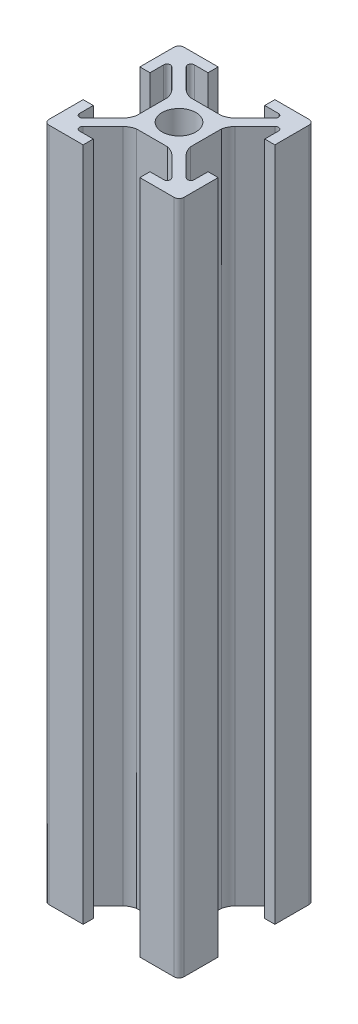
from build123d import *

# Parameters (mm, degrees)
SKETCH1_R           = 2.5
BOSS_EXTRUDE1_DEPTH = 100


with BuildPart() as part:
    # Sketch1 → Boss-Extrude1 (new body)
    with BuildSketch(Plane(origin=(0, 0, 0), x_dir=(1, 0, 0), z_dir=(0, 1, 0))):
        with BuildLine():
            Line((-3.610984523, 4.671644695), (-6.585786438, 7.646446609))
            ThreePointArc((-6.585786438, 7.646446609), (-6.694172813, 8.191341716), (-6.232233047, 8.5))
            Line((-6.232233047, 8.5), (-4.2, 8.5))
            Line((-4.2, 8.5), (-4.2, 10))
            Line((-4.2, 10), (-9.25, 10))
            ThreePointArc((-9.25, 10), (-9.780330086, 9.780330086), (-10, 9.25))
            Line((-10, 9.25), (-10, 4.2))
            Line((-10, 4.2), (-8.5, 4.2))
            Line((-8.5, 4.2), (-8.5, 6.232233047))
            ThreePointArc((-8.5, 6.232233047), (-8.191341716, 6.694172813), (-7.646446609, 6.585786438))
            Line((-7.646446609, 6.585786438), (-4.671644695, 3.610984523))
            ThreePointArc((-4.671644695, 3.610984523), (-4.244383234, 2.985253206), (-4, 2.268058063))
            Line((-4, 2.268058063), (-4, -2.268058063))
            ThreePointArc((-4, -2.268058063), (-4.244383234, -2.985253206), (-4.671644695, -3.610984523))
            Line((-4.671644695, -3.610984523), (-7.646446609, -6.585786438))
            ThreePointArc((-7.646446609, -6.585786438), (-8.191341716, -6.694172813), (-8.5, -6.232233047))
            Line((-8.5, -6.232233047), (-8.5, -4.2))
            Line((-8.5, -4.2), (-10, -4.2))
            Line((-10, -4.2), (-10, -9.25))
            ThreePointArc((-10, -9.25), (-9.780330086, -9.780330086), (-9.25, -10))
            Line((-9.25, -10), (-4.2, -10))
            Line((-4.2, -10), (-4.2, -8.5))
            Line((-4.2, -8.5), (-6.232233047, -8.5))
            ThreePointArc((-6.232233047, -8.5), (-6.694172813, -8.191341716), (-6.585786438, -7.646446609))
            Line((-6.585786438, -7.646446609), (-3.610984523, -4.671644695))
            ThreePointArc((-3.610984523, -4.671644695), (-2.985253206, -4.244383234), (-2.268058063, -4))
            Line((-2.268058063, -4), (2.268058063, -4))
            ThreePointArc((2.268058063, -4), (2.985253206, -4.244383234), (3.610984523, -4.671644695))
            Line((3.610984523, -4.671644695), (6.585786438, -7.646446609))
            ThreePointArc((6.585786438, -7.646446609), (6.694172813, -8.191341716), (6.232233047, -8.5))
            Line((6.232233047, -8.5), (4.2, -8.5))
            Line((4.2, -8.5), (4.2, -10))
            Line((4.2, -10), (9.25, -10))
            ThreePointArc((9.25, -10), (9.780330086, -9.780330086), (10, -9.25))
            Line((10, -9.25), (10, -4.2))
            Line((10, -4.2), (8.5, -4.2))
            Line((8.5, -4.2), (8.5, -6.232233047))
            ThreePointArc((8.5, -6.232233047), (8.191341716, -6.694172813), (7.646446609, -6.585786438))
            Line((7.646446609, -6.585786438), (4.671644695, -3.610984523))
            ThreePointArc((4.671644695, -3.610984523), (4.244383234, -2.985253206), (4, -2.268058063))
            Line((4, -2.268058063), (4, 2.268058063))
            ThreePointArc((4, 2.268058063), (4.244383234, 2.985253206), (4.671644695, 3.610984523))
            Line((4.671644695, 3.610984523), (7.646446609, 6.585786438))
            ThreePointArc((7.646446609, 6.585786438), (8.191341716, 6.694172813), (8.5, 6.232233047))
            Line((8.5, 6.232233047), (8.5, 4.2))
            Line((8.5, 4.2), (10, 4.2))
            Line((10, 4.2), (10, 9.25))
            ThreePointArc((10, 9.25), (9.780330086, 9.780330086), (9.25, 10))
            Line((9.25, 10), (4.2, 10))
            Line((4.2, 10), (4.2, 8.5))
            Line((4.2, 8.5), (6.232233047, 8.5))
            ThreePointArc((6.232233047, 8.5), (6.694172813, 8.191341716), (6.585786438, 7.646446609))
            Line((6.585786438, 7.646446609), (3.610984523, 4.671644695))
            ThreePointArc((3.610984523, 4.671644695), (2.985253206, 4.244383234), (2.268058063, 4))
            Line((2.268058063, 4), (-2.268058063, 4))
            ThreePointArc((-2.268058063, 4), (-2.985253206, 4.244383234), (-3.610984523, 4.671644695))
        make_face()
        Circle(SKETCH1_R, mode=Mode.SUBTRACT)
    extrude(amount=BOSS_EXTRUDE1_DEPTH)


solid = part.part
